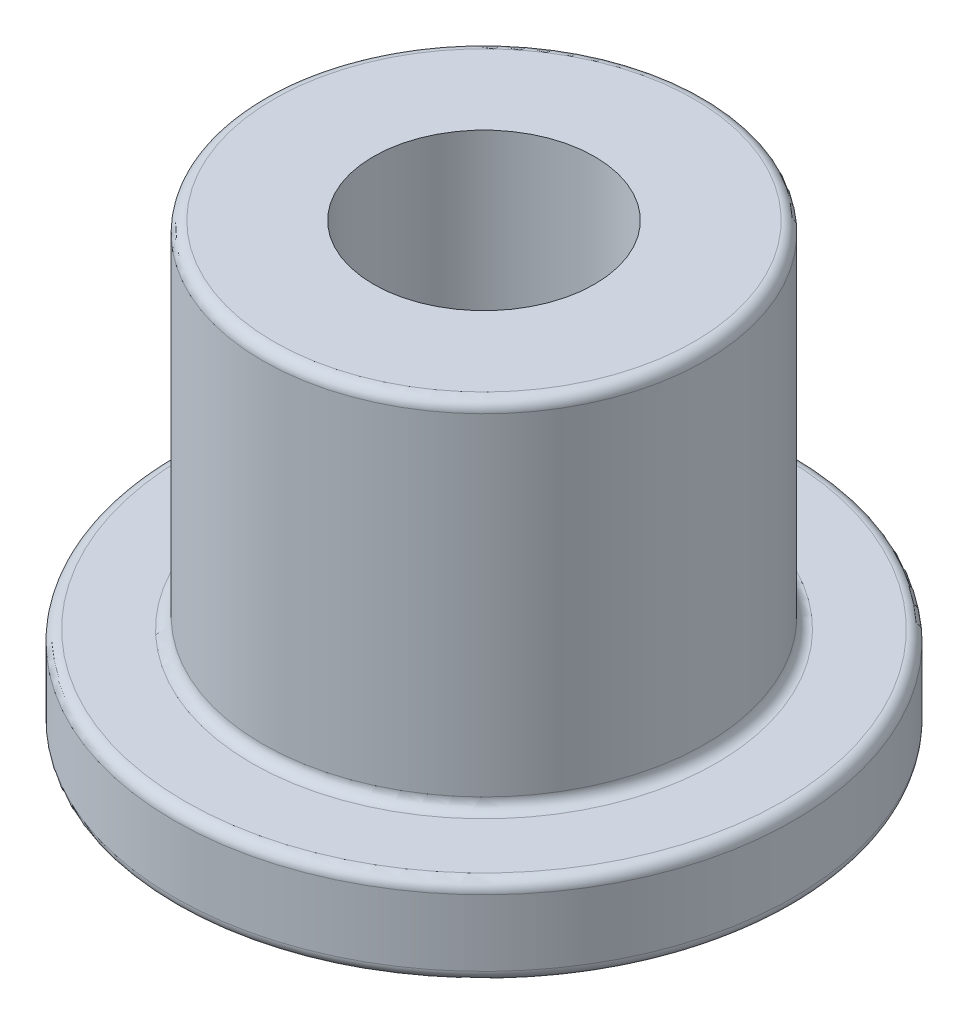
from build123d import *

# Parameters (mm, degrees)
CROQUIS1_R              = 7
SALIENTE_EXTRUIR1_DEPTH = 2
CROQUIS2_R              = 5
SALIENTE_EXTRUIR2_DEPTH = 8
CROQUIS3_R              = 2.5
CORTAR_EXTRUIR1_DEPTH   = 18
REDONDEO1_R             = 0.25


with BuildPart() as part:
    # Croquis1 → Saliente-Extruir1 (new body)
    with BuildSketch(Plane(origin=(0, 0, 0), x_dir=(1, 0, 0), z_dir=(0, 1, 0))):
        Circle(CROQUIS1_R)
    extrude(amount=SALIENTE_EXTRUIR1_DEPTH)

    # Croquis2 → Saliente-Extruir2 (add)
    with BuildSketch(Plane(origin=(0, 2, 0), x_dir=(1, 0, 0), z_dir=(0, 1, 0))):
        Circle(CROQUIS2_R)
    extrude(amount=SALIENTE_EXTRUIR2_DEPTH)

    # Croquis3 → Cortar-Extruir1 (cut)
    with BuildSketch(Plane(origin=(0, 10, 0), x_dir=(1, 0, 0), z_dir=(0, 1, 0))):
        Circle(CROQUIS3_R)
    extrude(amount=-CORTAR_EXTRUIR1_DEPTH, mode=Mode.SUBTRACT)

    # Redondeo1
    redondeo1_edges = [part.edges().sort_by_distance(p)[0] for p in [
        (-7, 0, 0),
        (-7, 2, 0),
        (-5, 2, 0),
        (-5, 10, 0),
    ]]
    fillet(redondeo1_edges, radius=REDONDEO1_R)


solid = part.part
